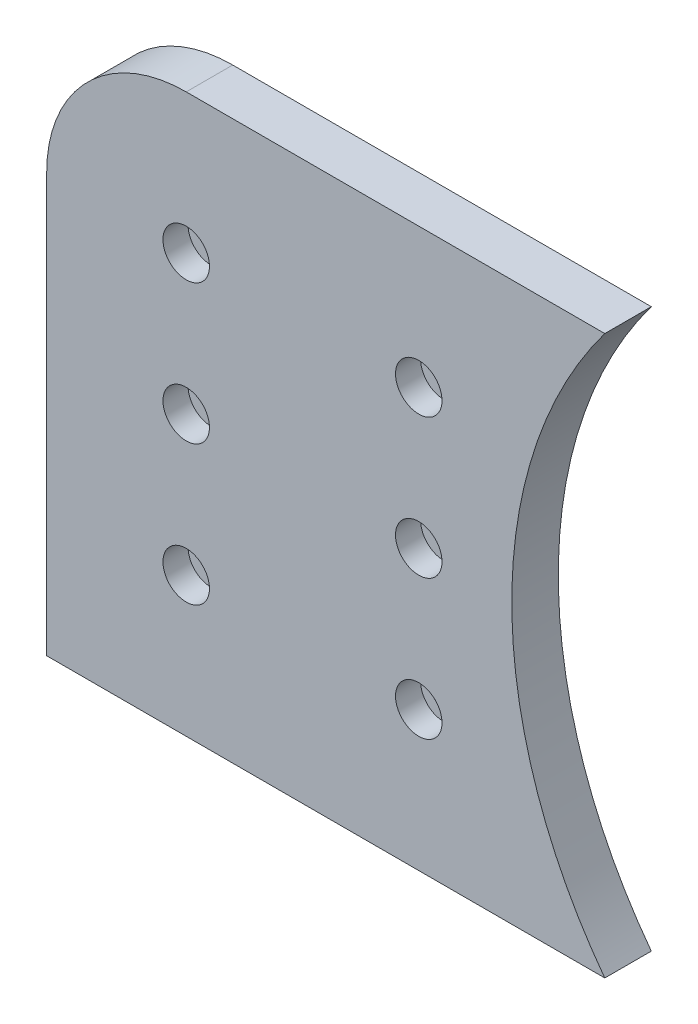
from build123d import *

# Parameters (mm, degrees)
AUFSATZ_LINEAR_AUSTRAGEN1_DEPTH                      = 5
VERRUNDUNG1_R                                        = 30
STIRNSENKUNG_F_R_M5_ZYLINDERSCHRAUBE_MIT_D           = 5.3
STIRNSENKUNG_F_R_M5_ZYLINDERSCHRAUBE_MIT_CBORE_D     = 10
STIRNSENKUNG_F_R_M5_ZYLINDERSCHRAUBE_MIT_CBORE_DEPTH = 5.4
LINEARES_MUSTER1_COUNT                               = 3
LINEARES_MUSTER1_PITCH                               = 30
LINEARES_MUSTER1_COUNT_DIR2                          = 2
LINEARES_MUSTER1_PITCH_DIR2                          = 50


with BuildPart() as part:
    # Skizze1 → Aufsatz-Linear austragen1 (new body, symmetric)
    with BuildSketch(Plane.XY):
        with BuildLine():
            Line((-120, 60), (0, 60))
            Line((0, 60), (0, -60))
            Line((0, -60), (-120, -60))
            ThreePointArc((-120, -60), (-100, 0), (-120, 60))
        make_face()
    extrude(amount=AUFSATZ_LINEAR_AUSTRAGEN1_DEPTH, both=True)

    # Verrundung1
    verrundung1_edges = [part.edges().sort_by_distance(p)[0] for p in [
        (0, 60, 0),
    ]]
    fillet(verrundung1_edges, radius=VERRUNDUNG1_R)

    # Stirnsenkung für M5 Zylinderschraube mit Innensechskant1 (through all)
    with Locations(Plane.XY.offset(5)):
        with Locations((-30, 30)):
            stirnsenkung_f_r_m5_zylinderschraube_mit = CounterBoreHole(STIRNSENKUNG_F_R_M5_ZYLINDERSCHRAUBE_MIT_D / 2, STIRNSENKUNG_F_R_M5_ZYLINDERSCHRAUBE_MIT_CBORE_D / 2, STIRNSENKUNG_F_R_M5_ZYLINDERSCHRAUBE_MIT_CBORE_DEPTH)

    # Lineares Muster1: Stirnsenkung f_r M5 Zylinderschraube mit 3 × 2
    with Locations(*[(-j * LINEARES_MUSTER1_PITCH_DIR2, -i * LINEARES_MUSTER1_PITCH, 0) for i in range(LINEARES_MUSTER1_COUNT) for j in range(LINEARES_MUSTER1_COUNT_DIR2) if (i, j) != (0, 0)]):
        add(stirnsenkung_f_r_m5_zylinderschraube_mit, mode=Mode.SUBTRACT)


with BuildPart() as body_2:
    # Spiegeln1: mirrored copy
    add(part.part.mirror(Plane(origin=(0, 60, 5), x_dir=(0, 0, 1), z_dir=(-1, 0, 0))))


solid = body_2.part
